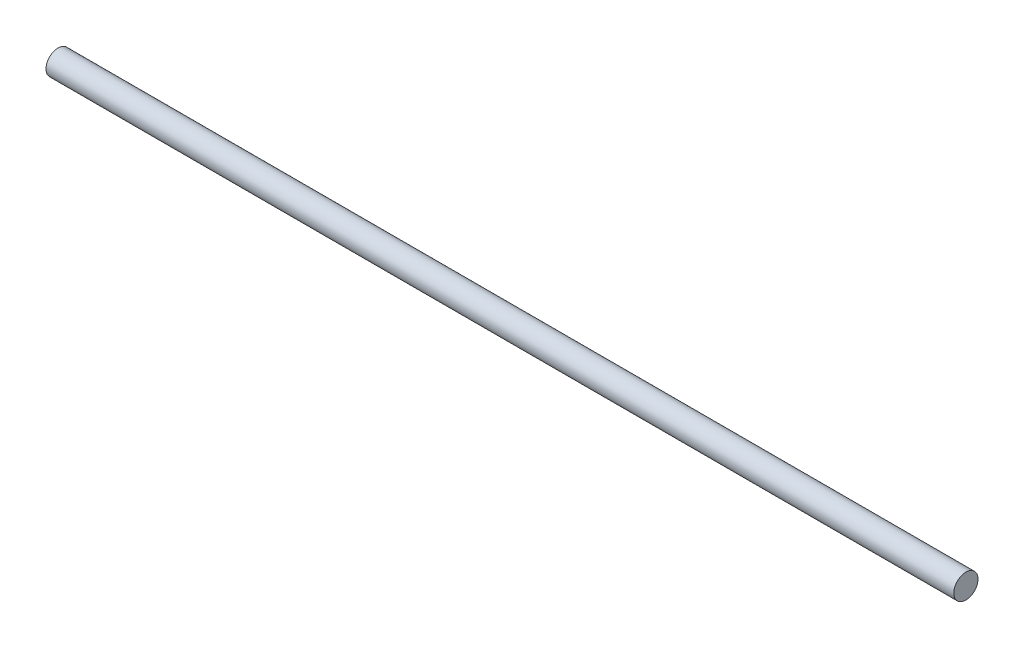
from build123d import *

# Parameters (mm, degrees)
SKETCH1_R           = 4
BOSS_EXTRUDE1_DEPTH = 300


with BuildPart() as part:
    # Sketch1 → Boss-Extrude1 (new body)
    with BuildSketch(Plane(origin=(0, 0, 0), x_dir=(0, 0, -1), z_dir=(1, 0, 0))):
        Circle(SKETCH1_R)
    extrude(amount=-BOSS_EXTRUDE1_DEPTH)


solid = part.part
